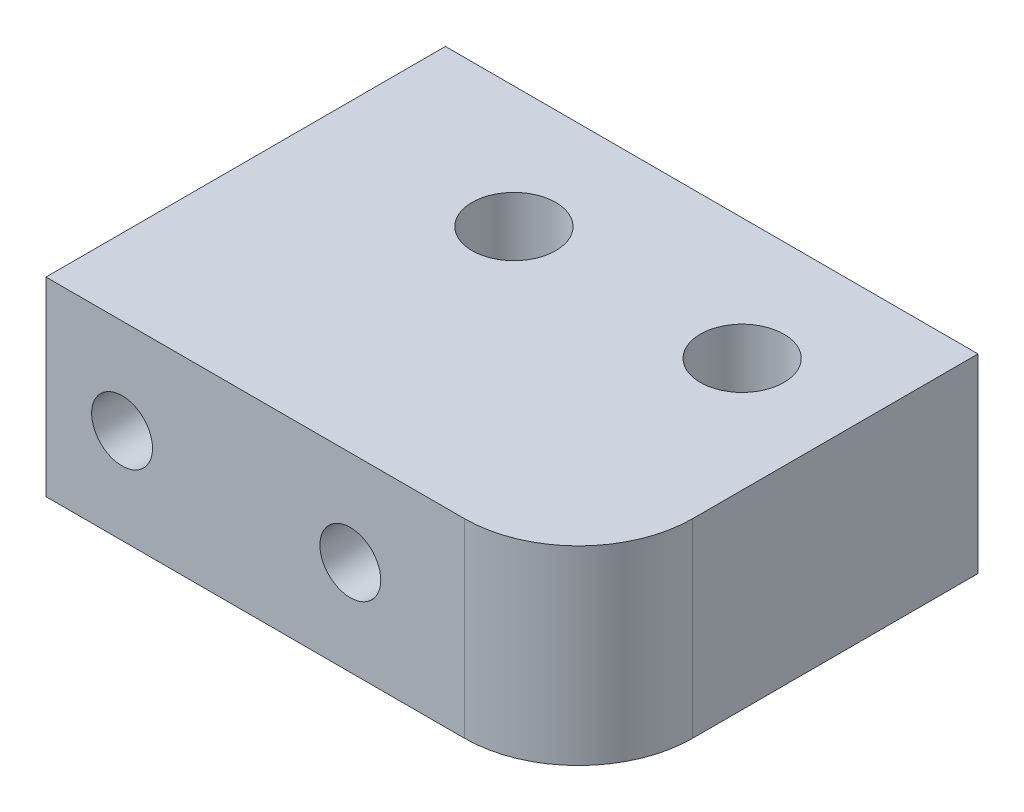
from build123d import *

# Parameters (mm, degrees)
SKETCH1_W           = 14
SKETCH1_H           = 10.5
BOSS_EXTRUDE1_DEPTH = 5
HOLE1_D             = 2.2
HOLE1_CBORE_D       = 4.2
HOLE1_CBORE_DEPTH   = 1.3
FILLET_2_R          = 3
M2X0_4_5_D          = 1.6


with BuildPart() as part:
    # Sketch1 → Boss-Extrude1 (new body)
    with BuildSketch(Plane(origin=(0, 0, 0), x_dir=(1, 0, 0), z_dir=(0, 1, 0))):
        Rectangle(SKETCH1_W, SKETCH1_H)
    extrude(amount=BOSS_EXTRUDE1_DEPTH)

    # Hole1 (through all)
    with Locations(Plane.XZ):
        with Locations((-2, -2.05), (4, -2.05)):
            CounterBoreHole(HOLE1_D / 2, HOLE1_CBORE_D / 2, HOLE1_CBORE_DEPTH)

    # ﾌｨﾚｯﾄ2
    fillet_2_edges = [part.edges().sort_by_distance(p)[0] for p in [
        (7, 2.5, 5.25),
    ]]
    fillet(fillet_2_edges, radius=FILLET_2_R)

    # M2x0.4 ねじ穴5 (through all)
    with Locations(Plane(origin=(-5, 2.5, 5.25), x_dir=(1, 0, 0), z_dir=(0, 0, 1))):
        with Locations((0, 0), (6, 0)):
            Hole(M2X0_4_5_D / 2)


solid = part.part
